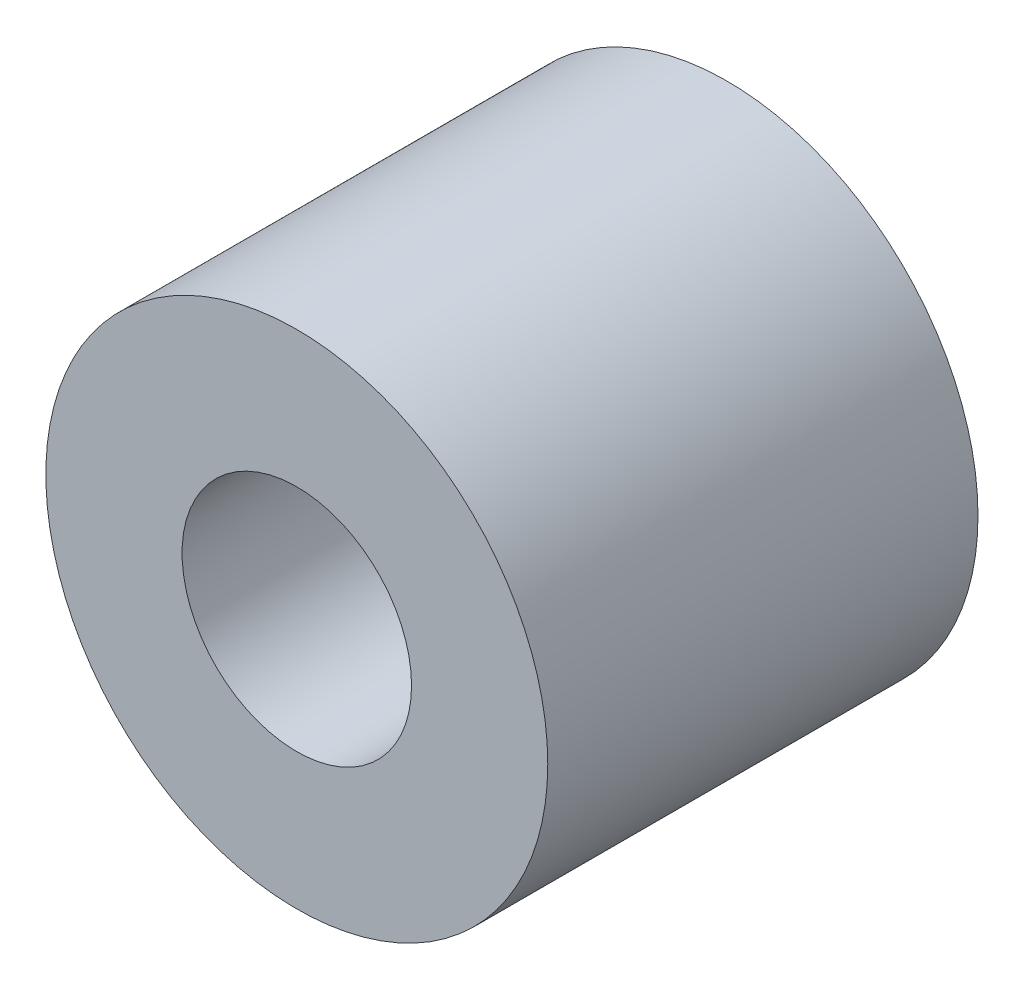
from build123d import *

# Parameters (mm, degrees)
CROQUIS1_R              = 3.5
CROQUIS1_R_2            = 1.6
SALIENTE_EXTRUIR1_DEPTH = 6


with BuildPart() as part:
    # Croquis1 → Saliente-Extruir1 (new body)
    with BuildSketch(Plane.XY):
        Circle(CROQUIS1_R)
        Circle(CROQUIS1_R_2, mode=Mode.SUBTRACT)
    extrude(amount=SALIENTE_EXTRUIR1_DEPTH)


solid = part.part
